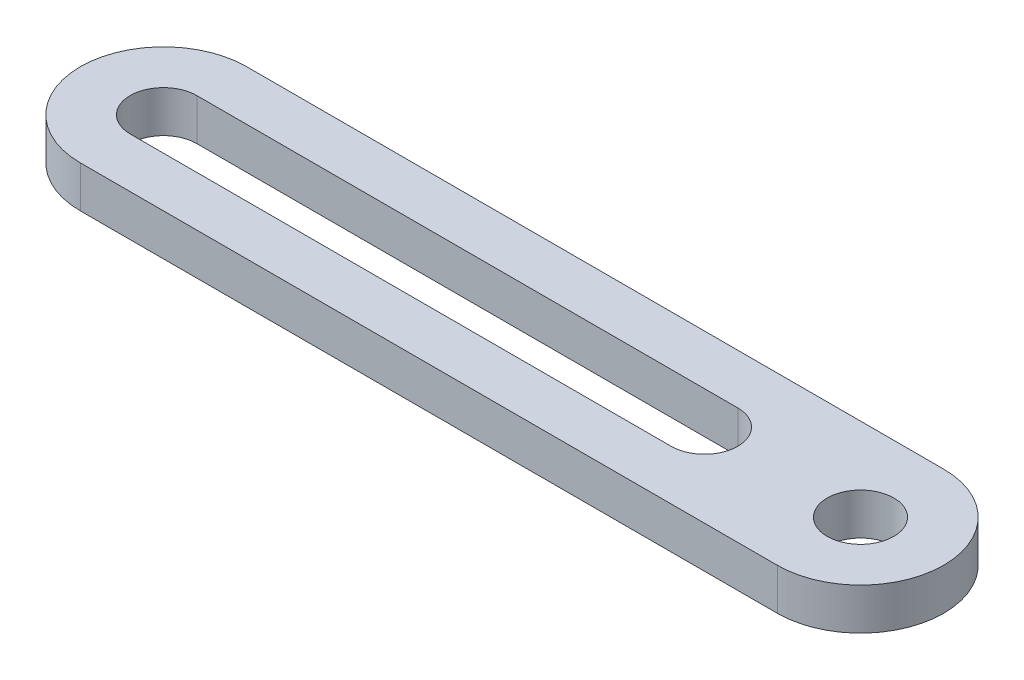
from build123d import *

# Parameters (mm, degrees)
SKETCH_1_R      = 1.6
EXTRUDE_1_DEPTH = 2


with BuildPart() as part:
    # 草图1 → 凸台-拉伸1 (new body)
    with BuildSketch(Plane(origin=(0, 0, 0), x_dir=(1, 0, 0), z_dir=(0, 1, 0))):
        with BuildLine():
            Line((0, -4), (-33.5, -4))
            ThreePointArc((-33.5, -4), (-37.5, 0), (-33.5, 4))
            Line((-33.5, 4), (0, 4))
            ThreePointArc((0, 4), (4, 0), (0, -4))
        make_face()
        Circle(SKETCH_1_R, mode=Mode.SUBTRACT)
        with BuildLine():
            Line((-33.5, 1.6), (-7.5, 1.6))
            ThreePointArc((-7.5, 1.6), (-5.9, 0), (-7.5, -1.6))
            Line((-7.5, -1.6), (-33.5, -1.6))
            ThreePointArc((-33.5, -1.6), (-35.1, 0), (-33.5, 1.6))
        make_face(mode=Mode.SUBTRACT)
    extrude(amount=EXTRUDE_1_DEPTH)


solid = part.part
